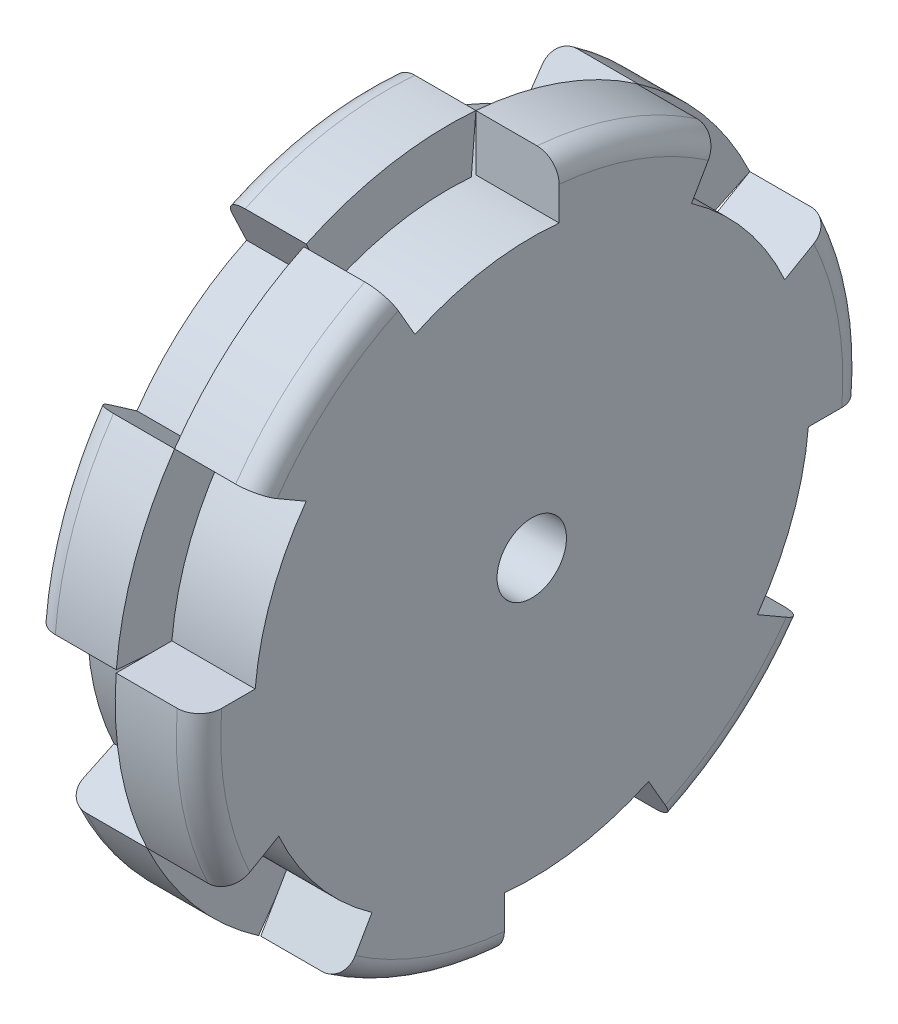
from build123d import *

# Parameters (mm, degrees)
SKETCH1_R           = 76.2
SKETCH1_R_2         = 7.9375
BOSS_EXTRUDE1_DEPTH = 38.1
FILLET1_R           = 5.08
CUT_EXTRUDE1_START  = -19.05
CUT_EXTRUDE1_DEPTH  = 19.05
CIRPATTERN1_COUNT   = 6
CUT_EXTRUDE4_DEPTH  = 19.05
CIRPATTERN2_COUNT   = 6


with BuildPart() as part:
    # Sketch1 → Boss-Extrude1 (new body)
    with BuildSketch(Plane(origin=(0, 0, 0), x_dir=(0, 0, -1), z_dir=(1, 0, 0))):
        Circle(SKETCH1_R)
        Circle(SKETCH1_R_2, mode=Mode.SUBTRACT)
    extrude(amount=BOSS_EXTRUDE1_DEPTH)

    # Fillet1
    fillet1_edges = [part.edges().sort_by_distance(p)[0] for p in [
        (38.1, 0, 76.2),
        (0, 0, 76.2),
    ]]
    fillet(fillet1_edges, radius=FILLET1_R)

    # Sketch2 → Cut-Extrude1 (cut)
    with BuildSketch(Plane(origin=(38.1, 0, 0), x_dir=(0, 0, -1), z_dir=(1, 0, 0)).offset(CUT_EXTRUDE1_START)):
        with BuildLine():
            Line((26.709059948, -57.609687698), (33.080292894, -68.644986868))
            ThreePointArc((33.080292894, -68.644986868), (13.89350873, -74.922696262), (-6.268432812, -75.941732599))
            Line((-6.268432812, -75.941732599), (-6.268432812, -63.189846891))
            ThreePointArc((-6.268432812, -63.189846891), (10.594307603, -62.609988392), (26.709059948, -57.609687698))
        make_face()
    cut_extrude1 = extrude(amount=CUT_EXTRUDE1_DEPTH, mode=Mode.SUBTRACT)

    # CirPattern1: Cut-Extrude1 ×6 about axis
    cirpattern1_axis = Axis((33.02, 0, 0), (-1, 0, 0))
    for i in range(1, CIRPATTERN1_COUNT):
        add(cut_extrude1.rotate(cirpattern1_axis, i * 360 / CIRPATTERN1_COUNT), mode=Mode.SUBTRACT)

    # Sketch3 → Cut-Extrude4 (cut)
    with BuildSketch(Plane.ZY):
        with BuildLine():
            Line((-27.111735655, -57.421283421), (-32.534082786, -68.905540106))
            ThreePointArc((-32.534082786, -68.905540106), (-49.25957689, -58.137200522), (-62.628112235, -43.4069068))
            Line((-62.628112235, -43.4069068), (-52.190093529, -36.172422333))
            ThreePointArc((-52.190093529, -36.172422333), (-41.049647409, -48.447667102), (-27.111735655, -57.421283421))
        make_face()
    cut_extrude4 = extrude(amount=-CUT_EXTRUDE4_DEPTH, mode=Mode.SUBTRACT)

    # CirPattern2: Cut-Extrude4 ×6 about axis
    cirpattern2_axis = Axis((0, 0, 0), (-1, 0, 0))
    for i in range(1, CIRPATTERN2_COUNT):
        add(cut_extrude4.rotate(cirpattern2_axis, i * 360 / CIRPATTERN2_COUNT), mode=Mode.SUBTRACT)


solid = part.part
